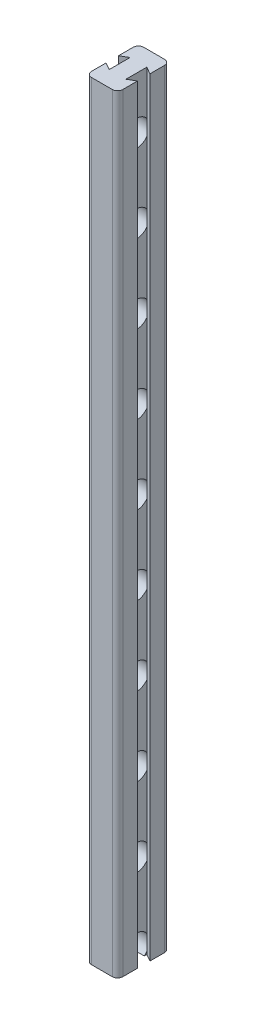
from build123d import *

# Parameters (mm, degrees)
BOSS_EXTRUDE1_DEPTH     = 735
SKETCH3_R               = 12.5
CUT_EXTRUDE2_DEPTH      = 8
CUT_EXTRUDE2_DEPTH_BACK = 8
FILLET1_R               = 5


with BuildPart() as part:
    # Sketch1 → Boss-Extrude1 (new body)
    with BuildSketch(Plane(origin=(0, 0, 0), x_dir=(1, 0, 0), z_dir=(0, 1, 0))):
        Polygon((15, 25), (15, 5.958548116), (8, 10), (8, -10), (15, -5.958548116), (15, -25), (-15, -25), (-15, -5.958548116), (-8, -10), (-8, 10), (-15, 5.958548116), (-15, 25), align=None)
    extrude(amount=BOSS_EXTRUDE1_DEPTH)

    # Sketch3 → Cut-Extrude2 (cut, two sides)
    with BuildSketch(Plane(origin=(0, 0, 0), x_dir=(0, 0, -1), z_dir=(1, 0, 0))) as cut_extrude2_sk:
        with Locations((0, 685)):
            Circle(SKETCH3_R)
        with Locations((0, 610)):
            Circle(SKETCH3_R)
        with Locations((0, 535)):
            Circle(SKETCH3_R)
        with Locations((0, 460)):
            Circle(SKETCH3_R)
        with Locations((0, 385)):
            Circle(SKETCH3_R)
        with Locations((0, 310)):
            Circle(SKETCH3_R)
        with Locations((0, 235)):
            Circle(SKETCH3_R)
        with Locations((0, 160)):
            Circle(SKETCH3_R)
        with Locations((0, 85)):
            Circle(SKETCH3_R)
        with Locations((0, 10)):
            Circle(SKETCH3_R)
        with Locations((0, -65)):
            Circle(SKETCH3_R)
    extrude(amount=CUT_EXTRUDE2_DEPTH, mode=Mode.SUBTRACT)
    extrude(cut_extrude2_sk.sketch, amount=-CUT_EXTRUDE2_DEPTH_BACK, mode=Mode.SUBTRACT)

    # Fillet1
    fillet1_edges = [part.edges().sort_by_distance(p)[0] for p in [
        (15, 367.5, -25),
        (15, 367.5, 25),
        (-15, 367.5, 25),
        (-15, 367.5, -25),
    ]]
    fillet(fillet1_edges, radius=FILLET1_R)


solid = part.part
